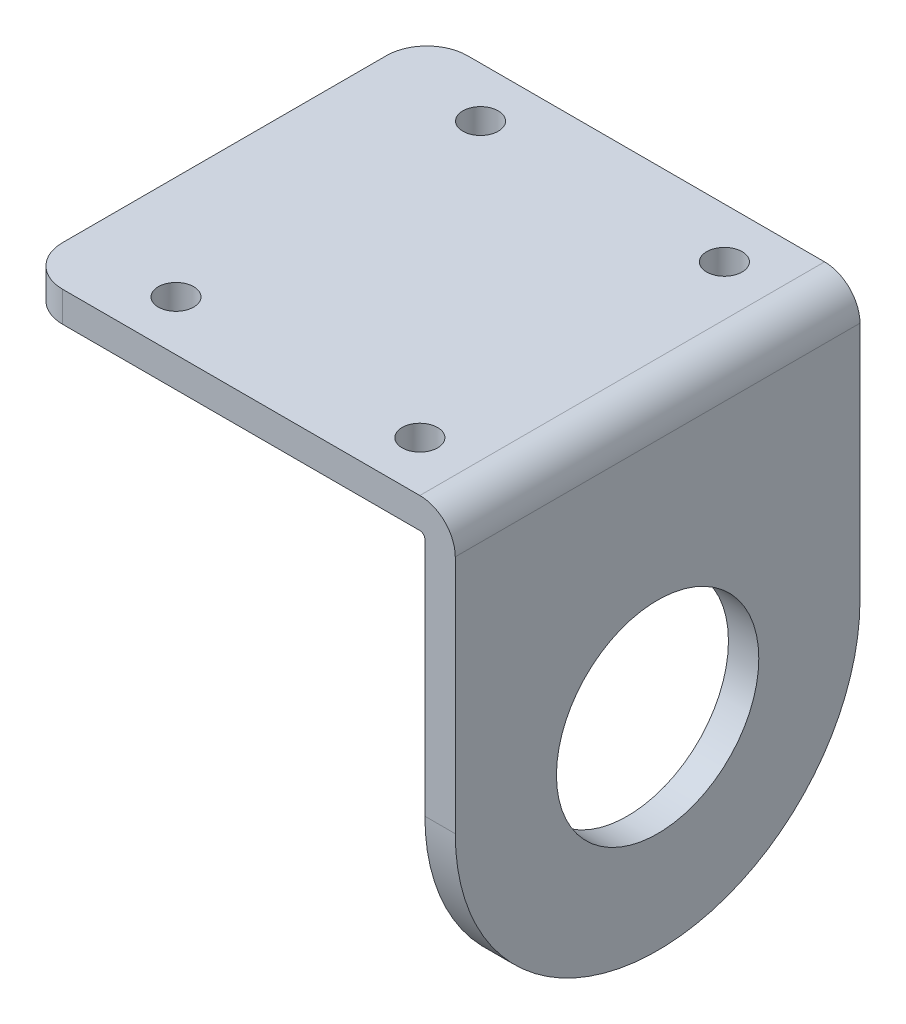
from build123d import *

# Parameters (mm, degrees)
SKETCH1_R           = 20
SKETCH1_R_2         = 10
BOSS_EXTRUDE1_DEPTH = 3
SKETCH2_W           = 40
SKETCH2_H           = 3
BOSS_EXTRUDE2_DEPTH = 42.8
FILLET1_R           = 0.5
FILLET2_R           = 3.5
FILLET3_R           = 4
SKETCH3_R           = 1.75
CUT_EXTRUDE1_DEPTH  = 10


with BuildPart() as part:
    # Sketch1 → Boss-Extrude1 (new body)
    with BuildSketch(Plane(origin=(0, 0, 0), x_dir=(0, 0, -1), z_dir=(1, 0, 0))):
        with BuildLine():
            Line((-20, 27.2), (-20, 0))
            ThreePointArc((-20, 0), (0, 20), (20, 0))
            Line((20, 0), (20, 27.2))
            Line((20, 27.2), (-20, 27.2))
        make_face()
        Circle(SKETCH1_R)
        Circle(SKETCH1_R_2, mode=Mode.SUBTRACT)
    extrude(amount=BOSS_EXTRUDE1_DEPTH)

    # Sketch2 → Boss-Extrude2 (add)
    with BuildSketch(Plane(origin=(3, 0, 0), x_dir=(0, 0, -1), z_dir=(1, 0, 0))):
        with Locations((0, 25.7)):
            Rectangle(SKETCH2_W, SKETCH2_H)
    extrude(amount=-BOSS_EXTRUDE2_DEPTH)

    # Fillet1
    fillet1_edges = [part.edges().sort_by_distance(p)[0] for p in [
        (0, 24.2, 0),
    ]]
    fillet(fillet1_edges, radius=FILLET1_R)

    # Fillet2
    fillet2_edges = [part.edges().sort_by_distance(p)[0] for p in [
        (3, 27.2, 0),
    ]]
    fillet(fillet2_edges, radius=FILLET2_R)

    # Fillet3
    fillet3_edges = [part.edges().sort_by_distance(p)[0] for p in [
        (-39.8, 25.7, 20),
        (-39.8, 25.7, -20),
    ]]
    fillet(fillet3_edges, radius=FILLET3_R)

    # Sketch3 → Cut-Extrude1 (cut)
    with BuildSketch(Plane(origin=(0, 27.2, 0), x_dir=(1, 0, 0), z_dir=(0, 1, 0))):
        with Locations((-29.55, 15.05)):
            Circle(SKETCH3_R)
        with Locations((-5.45, 15.05)):
            Circle(SKETCH3_R)
        with Locations((-29.55, -15.05)):
            Circle(SKETCH3_R)
        with Locations((-5.45, -15.05)):
            Circle(SKETCH3_R)
    extrude(amount=-CUT_EXTRUDE1_DEPTH, mode=Mode.SUBTRACT)


solid = part.part
